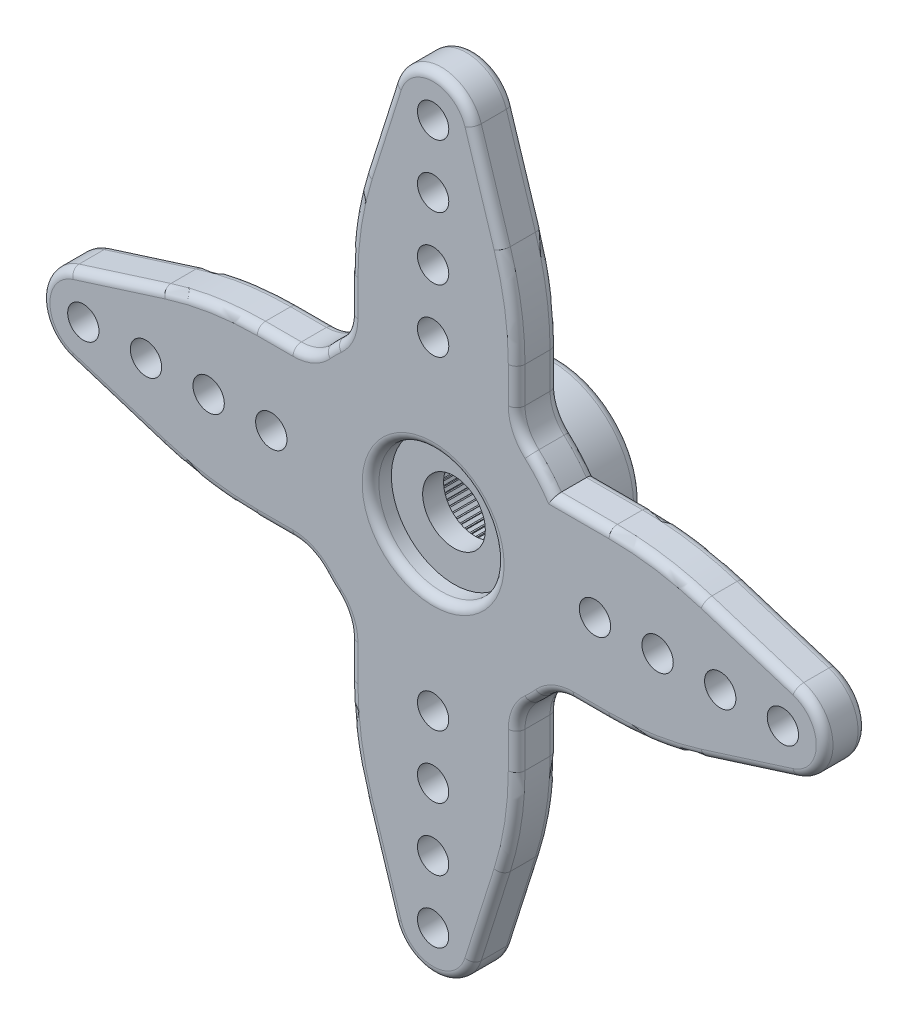
from build123d import *

# Parameters (mm, degrees)
SKETCH1_R                = 7
SKETCH1_R_2              = 1.5
SKETCH1_R_3              = 2
BOSS_EXTRUDE1_DEPTH      = 2
FILLET1_R                = 15
SKETCH2_R                = 0.75
CUT_EXTRUDE1_DEPTH       = 3
CIRPATTERN2_COUNT        = 4
FILLET1_OF_CIRPATTERN2_R = 15
FILLET2_R                = 2
SKETCH3_R                = 3
CUT_EXTRUDE2_DEPTH       = 1
SKETCH4_R                = 4
SKETCH4_R_2              = 3
BOSS_EXTRUDE2_DEPTH      = 4
SKETCH5_W                = 0.05
SKETCH5_H                = 0.5
BOSS_EXTRUDE3_DEPTH      = 4
CIRPATTERN3_COUNT        = 80
FILLET3_R                = 0.4


with BuildPart() as part:
    # Sketch1 → Boss-Extrude1 (new body)
    with BuildSketch(Plane.XY):
        Circle(SKETCH1_R)
        Circle(SKETCH1_R_2, mode=Mode.SUBTRACT)
        with BuildLine():
            Line((-1.906651599, 17.353887141), (-4, 10.744562647))
            Line((-4, 10.744562647), (-4, 5.744562647))
            ThreePointArc((-4, 5.744562647), (0, 7), (4, 5.744562647))
            Line((4, 5.744562647), (4, 10.744562647))
            Line((4, 10.744562647), (1.906651599, 17.353887141))
            ThreePointArc((1.906651599, 17.353887141), (1.976525132, 17.055529705), (2, 16.75))
            ThreePointArc((2, 16.75), (-0.305529705, 14.773474868), (-1.906651599, 17.353887141))
        make_face()
        with Locations((0, 16.75)):
            Circle(SKETCH1_R_3)
    boss_extrude1 = extrude(amount=BOSS_EXTRUDE1_DEPTH)

    # Fillet1
    fillet1_edges = [part.edges().sort_by_distance(p)[0] for p in [
        (-4, 10.744562647, 1),
        (4, 10.744562647, 1),
    ]]
    fillet(fillet1_edges, radius=FILLET1_R)

    # Sketch2 → Cut-Extrude1 (cut, through all)
    with BuildSketch(Plane.XY.offset(2)):
        with Locations((0, 16.75)):
            Circle(SKETCH2_R)
        with Locations((0, 13.75)):
            Circle(SKETCH2_R)
        with Locations((0, 10.75)):
            Circle(SKETCH2_R)
        with Locations((0, 7.75)):
            Circle(SKETCH2_R)
    cut_extrude1 = extrude(amount=-CUT_EXTRUDE1_DEPTH, mode=Mode.SUBTRACT)

    # CirPattern2: Boss-Extrude1, Cut-Extrude1 ×4 about axis
    cirpattern2_axis = Axis((0, 0, 0), (0, 0, 1))
    for i in range(1, CIRPATTERN2_COUNT):
        add(boss_extrude1.rotate(cirpattern2_axis, i * 360 / CIRPATTERN2_COUNT))
        add(cut_extrude1.rotate(cirpattern2_axis, i * 360 / CIRPATTERN2_COUNT), mode=Mode.SUBTRACT)

    # Fillet1 of CirPattern2
    fillet1_of_cirpattern2_edges = [part.edges().sort_by_distance(p)[0] for p in [
        (-10.744562647, -4, 1),
        (-10.744562647, 4, 1),
        (4, -10.744562647, 1),
        (-4, -10.744562647, 1),
        (10.744562647, 4, 1),
        (10.744562647, -4, 1),
    ]]
    fillet(fillet1_of_cirpattern2_edges, radius=FILLET1_OF_CIRPATTERN2_R)

    # Fillet2
    fillet2_edges = [part.edges().sort_by_distance(p)[0] for p in [
        (-4, 5.744562647, 1),
        (4, 5.744562647, 1),
        (4, -5.744562647, 1),
        (-5.744562647, -4, 1),
        (-5.744562647, 4, 1),
        (5.744562647, -4, 1),
        (-4, -5.744562647, 1),
    ]]
    fillet(fillet2_edges, radius=FILLET2_R)

    # Sketch3 → Cut-Extrude2 (cut)
    with BuildSketch(Plane.XY.offset(2)):
        Circle(SKETCH3_R)
    extrude(amount=-CUT_EXTRUDE2_DEPTH, mode=Mode.SUBTRACT)

    # Sketch4 → Boss-Extrude2 (add)
    with BuildSketch(Plane(origin=(0, 0, 0), x_dir=(-1, 0, 0), z_dir=(0, 0, -1))):
        Circle(SKETCH4_R)
        Circle(SKETCH4_R_2, mode=Mode.SUBTRACT)
    extrude(amount=BOSS_EXTRUDE2_DEPTH)

    # Sketch5 → Boss-Extrude3 (add)
    with BuildSketch(Plane(origin=(0, 0, -4), x_dir=(-1, 0, 0), z_dir=(0, 0, -1))):
        with Locations((0, -3.144105088)):
            Rectangle(SKETCH5_W, SKETCH5_H)
    boss_extrude3 = extrude(amount=-BOSS_EXTRUDE3_DEPTH)

    # CirPattern3: Boss-Extrude3 ×80 about axis
    cirpattern3_axis = Axis((0, 0, 0), (0, 0, 1))
    for i in range(1, CIRPATTERN3_COUNT):
        add(boss_extrude3.rotate(cirpattern3_axis, i * 360 / CIRPATTERN3_COUNT))

    # Fillet3
    fillet3_edges = [part.edges().sort_by_distance(p)[0] for p in [
        (-7.567039169, -4, 0),
        (-7.567039169, -4, 2),
        (-7.567039169, 4, 0),
        (-10.717347197, 3.823938493, 0),
        (-10.717347197, -3.823938493, 0),
        (-7.567039169, 4, 2),
        (-10.717347197, 3.823938493, 2),
        (-10.717347197, -3.823938493, 2),
        (4, -7.567039169, 0),
        (4, -7.567039169, 2),
        (-4, -7.567039169, 0),
        (-3.823938493, -10.717347197, 0),
        (3.823938493, -10.717347197, 0),
        (-4, -7.567039169, 2),
        (-3.823938493, -10.717347197, 2),
        (3.823938493, -10.717347197, 2),
        (7.085218526, 4, 0),
        (7.085218526, 4, 2),
        (7.567039169, -4, 0),
        (10.717347197, -3.823938493, 0),
        (10.717347197, 3.823938493, 0),
        (7.567039169, -4, 2),
        (10.717347197, -3.823938493, 2),
        (10.717347197, 3.823938493, 2),
        (2.603269296, 15.154457554, 2),
        (0, 18.75, 2),
        (4.949747468, -4.949747468, 0),
        (4.949747468, -4.949747468, 2),
        (-4.949747468, 4.949747468, 0),
        (-4.949747468, 4.949747468, 2),
        (-4.949747468, -4.949747468, 0),
        (-4.949747468, -4.949747468, 2),
        (-4, 7.567039169, 0),
        (-4, 7.567039169, 2),
        (5.891707352, -4.174258142, 0),
        (5.891707352, -4.174258142, 2),
        (4.174258142, -5.891707352, 0),
        (4.174258142, -5.891707352, 2),
        (-5.891707352, 4.174258142, 0),
        (-5.891707352, 4.174258142, 2),
        (-4.174258142, -5.891707352, 0),
        (-4.174258142, -5.891707352, 2),
        (-5.891707352, -4.174258142, 0),
        (-5.891707352, -4.174258142, 2),
        (4.174258142, 5.891707352, 0),
        (4.174258142, 5.891707352, 2),
        (-4.174258142, 5.891707352, 0),
        (-4.174258142, 5.891707352, 2),
        (-2.603269296, 15.154457554, 2),
        (4, 7.567039169, 0),
        (3.823938493, 10.717347197, 0),
        (-3.823938493, 10.717347197, 0),
        (-3, 0, 2),
        (4, 7.567039169, 2),
        (4, 0, 0),
        (3.823938493, 10.717347197, 2),
        (4, 0, -4),
        (-3.823938493, 10.717347197, 2),
        (5.241087255, 4.640151332, 0),
        (5.241087255, 4.640151332, 2),
        (-18.75, 0, 2),
        (-15.154457554, -2.603269296, 2),
        (0, -18.75, 2),
        (2.603269296, -15.154457554, 2),
        (18.75, 0, 2),
        (15.154457554, 2.603269296, 2),
        (-15.154457554, 2.603269296, 0),
        (-2.603269296, -15.154457554, 0),
        (15.154457554, -2.603269296, 0),
        (-15.154457554, 2.603269296, 2),
        (-18.75, 0, 0),
        (-15.154457554, -2.603269296, 0),
        (18.75, 0, 0),
        (15.154457554, -2.603269296, 2),
        (15.154457554, 2.603269296, 0),
        (-2.603269296, -15.154457554, 2),
        (0, -18.75, 0),
        (2.603269296, -15.154457554, 0),
        (-2.603269296, 15.154457554, 0),
        (0, 18.75, 0),
        (2.603269296, 15.154457554, 0),
    ]]
    fillet(fillet3_edges, radius=FILLET3_R)


solid = part.part
